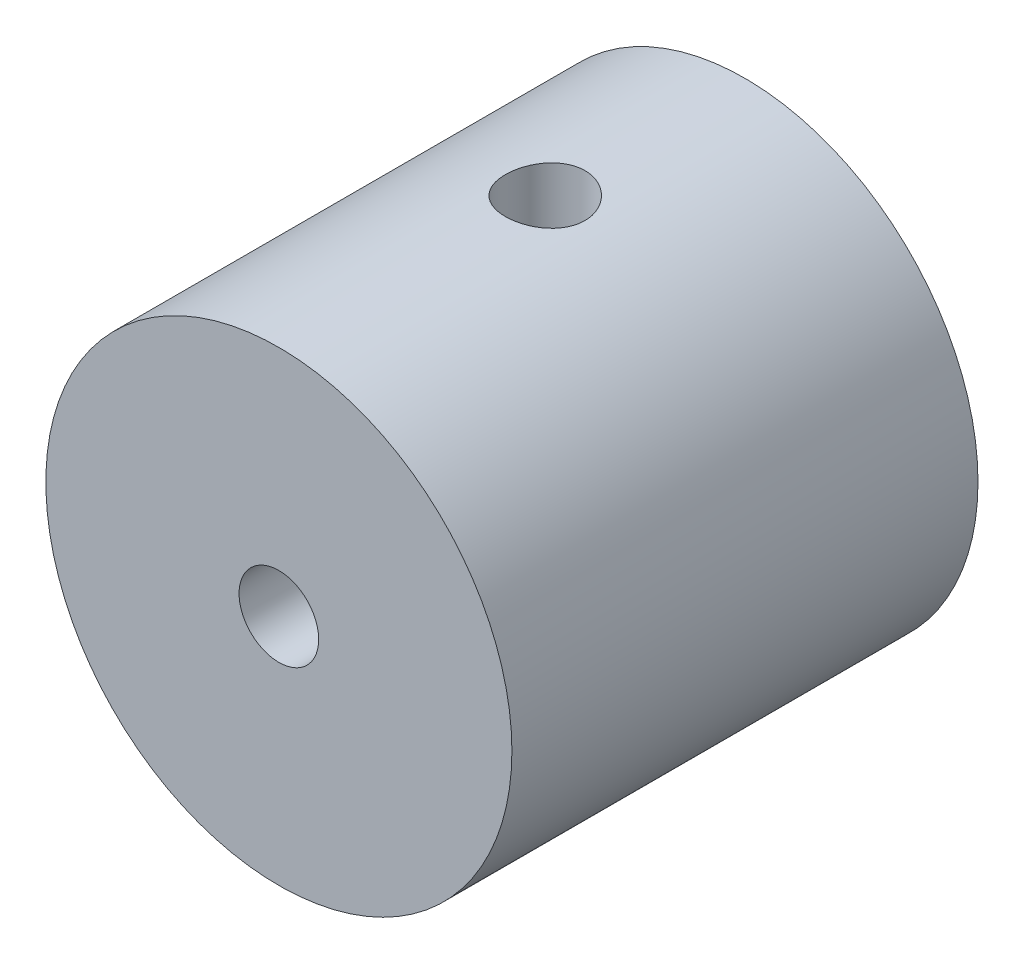
from build123d import *

# Parameters (mm, degrees)
SKETCH2_R              = 11.1125
BOSS_EXTRUDE1_DEPTH    = 22.225
F_10_24_TAPPED_HOLE1_D = 3.7973
SKETCH7_W              = 1.89865
SKETCH7_H              = 11.1125
F_10_24_TAPPED_HOLE3_D = 3.7973


with BuildPart() as part:
    # Sketch2 → Boss-Extrude1 (new body)
    with BuildSketch(Plane.XY):
        Circle(SKETCH2_R)
    extrude(amount=-BOSS_EXTRUDE1_DEPTH)

    # #10-24 Tapped Hole1 (through all)
    with Locations(Plane.XY):
        with Locations((0, 0)):
            Hole(F_10_24_TAPPED_HOLE1_D / 2)

    # Sketch7 → #10-24 Tapped Hole2 (revolve, cut)
    with BuildSketch(Plane(origin=(0, 0, -12.7), x_dir=(0, 0, -1), z_dir=(1, 0, 0))):
        with Locations((0.949325, 5.55625)):
            Rectangle(SKETCH7_W, SKETCH7_H)
    revolve(axis=Axis((0, -6.35, -12.7), (0, 1, 0)), mode=Mode.SUBTRACT)

    # #10-24 Tapped Hole3 (through all)
    with Locations(Plane(origin=(0, 0, 0), x_dir=(1, 0, 0), z_dir=(0, 1, 0))):
        with Locations((0, 12.7)):
            Hole(F_10_24_TAPPED_HOLE3_D / 2)


solid = part.part
